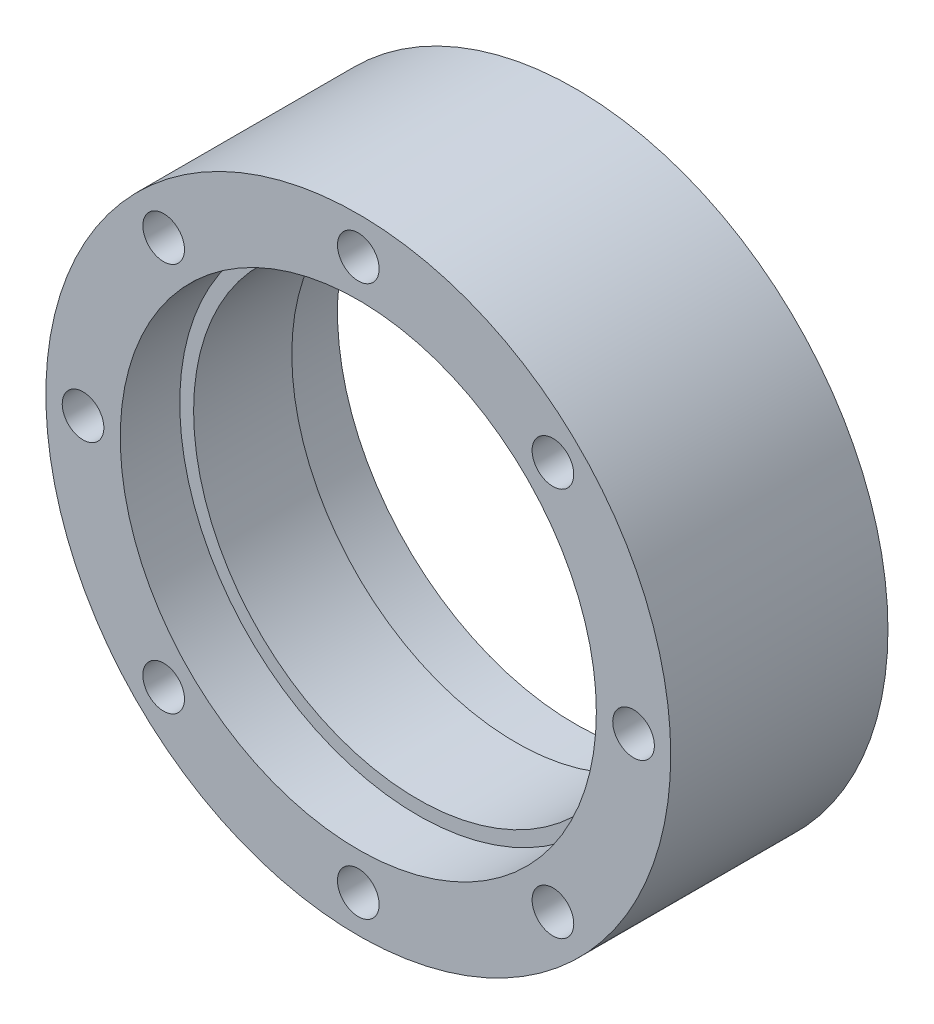
from build123d import *

# Parameters (mm, degrees)
SKETCH3_R          = 1.4
CUT_EXTRUDE2_DEPTH = 8.3
CUT_EXTRUDE4_START = -2.5
SKETCH4_R          = 2.35
CUT_EXTRUDE4_DEPTH = 3.5
CHAMFER1_SIZE      = 0.1
CIRPATTERN3_COUNT  = 4
CIRPATTERN2_COUNT  = 8


with BuildPart() as part:
    # Sketch7 → Revolve1 (revolve)
    with BuildSketch(Plane(origin=(0, 0, 0), x_dir=(1, 0, 0), z_dir=(0, 1, 0))):
        Polygon((16, 7.3), (16, 3.3), (15.07, 3.3), (15.07, -3.3), (16, -3.3), (16, -7.3), (21, -7.3), (21, 7.3), align=None)
    revolve(axis=Axis((0, 0, 8.03), (0, 0, -1)))

    # Sketch3 → Cut-Extrude2 (cut, symmetric)
    with BuildSketch(Plane.XY):
        with Locations((0, 18.5)):
            Circle(SKETCH3_R)
    cut_extrude2 = extrude(amount=CUT_EXTRUDE2_DEPTH, both=True, mode=Mode.SUBTRACT)

    # Sketch4 → Cut-Extrude4 (cut)
    with BuildSketch(Plane(origin=(0, 0, -7.3), x_dir=(-1, 0, 0), z_dir=(0, 0, -1)).offset(CUT_EXTRUDE4_START)):
        with Locations((0, 18.5)):
            Circle(SKETCH4_R)
    cut_extrude4 = extrude(amount=CUT_EXTRUDE4_DEPTH, mode=Mode.SUBTRACT)

    # Chamfer1
    chamfer1_edges = [part.edges().sort_by_distance(p)[0] for p in [
        (-1.4, 18.5, -4.8),
    ]]
    chamfer(chamfer1_edges, length=CHAMFER1_SIZE)

    # CirPattern3: Cut-Extrude4 ×4 about axis
    cirpattern3_axis = Axis((0, 0, 0), (0, 0, 1))
    for i in range(1, CIRPATTERN3_COUNT):
        add(cut_extrude4.rotate(cirpattern3_axis, i * 360 / CIRPATTERN3_COUNT), mode=Mode.SUBTRACT)

    # CirPattern2: Cut-Extrude2 ×8 about axis
    cirpattern2_axis = Axis((0, 0, 0), (0, 0, 1))
    for i in range(1, CIRPATTERN2_COUNT):
        add(cut_extrude2.rotate(cirpattern2_axis, i * 360 / CIRPATTERN2_COUNT), mode=Mode.SUBTRACT)


solid = part.part
